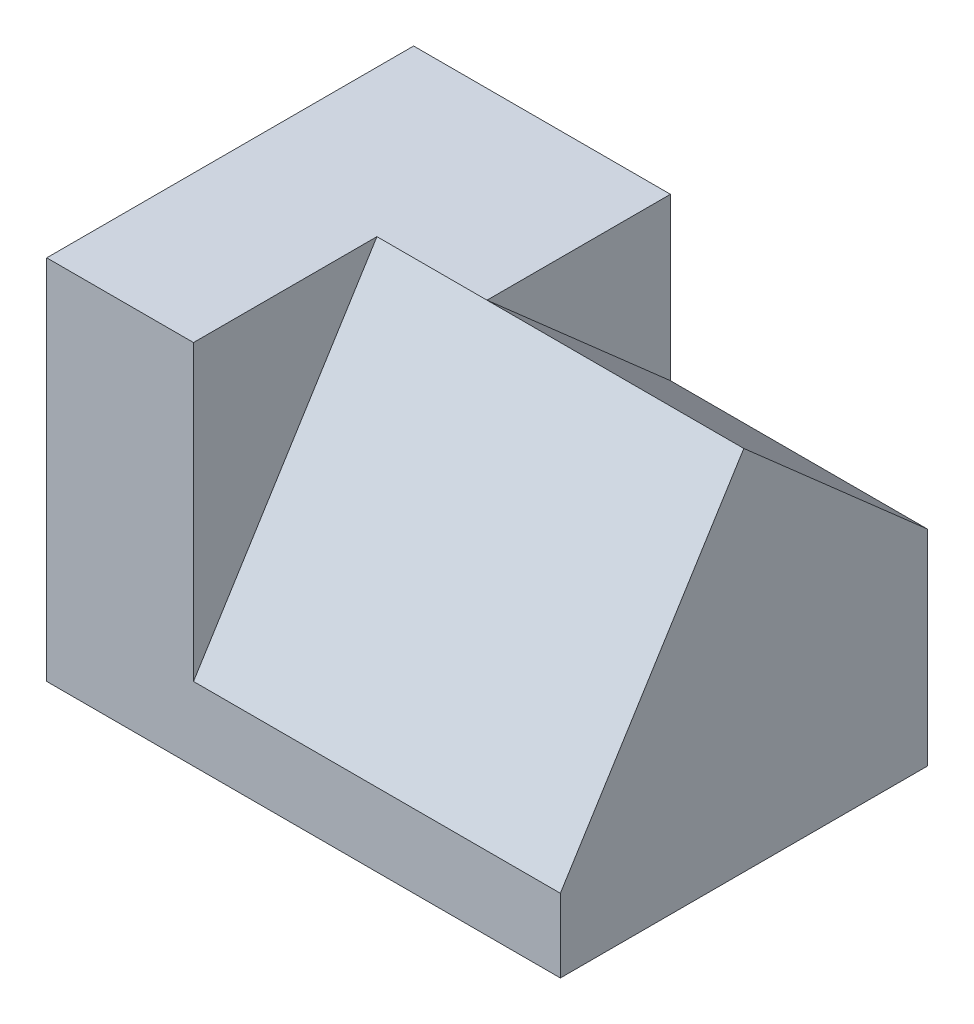
from build123d import *

# Parameters (mm, degrees)
SKETCH1_W           = 70
SKETCH1_H           = 50
BOSS_EXTRUDE1_DEPTH = 10
BOSS_EXTRUDE2_DEPTH = 40
BOSS_EXTRUDE3_DEPTH = 50


with BuildPart() as part:
    # Sketch1 → Boss-Extrude1 (new body)
    with BuildSketch(Plane(origin=(0, 0, 0), x_dir=(1, 0, 0), z_dir=(0, 1, 0))):
        Rectangle(SKETCH1_W, SKETCH1_H)
    extrude(amount=BOSS_EXTRUDE1_DEPTH)

    # Sketch3 → Boss-Extrude2 (add)
    with BuildSketch(Plane(origin=(0, 10, 0), x_dir=(1, 0, 0), z_dir=(0, 1, 0))):
        Polygon((-35, 25), (0, 25), (0, 0), (-15, 0), (-15, -25), (-35, -25), align=None)
    extrude(amount=BOSS_EXTRUDE2_DEPTH)

    # Sketch4 → Boss-Extrude3 (add)
    with BuildSketch(Plane(origin=(35, 0, 0), x_dir=(0, 0, -1), z_dir=(1, 0, 0))):
        Polygon((25, 10), (25, 28), (0, 50), (-25, 10), align=None)
    extrude(amount=-BOSS_EXTRUDE3_DEPTH)


solid = part.part
